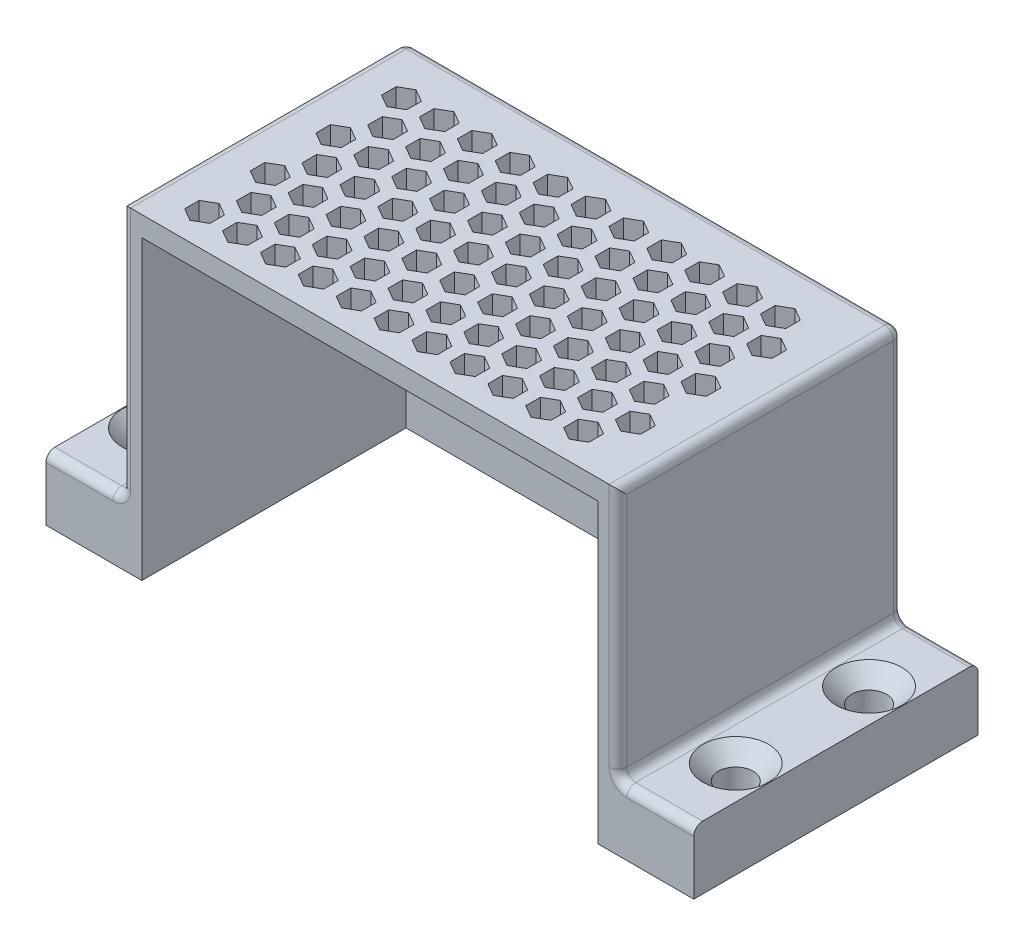
from build123d import *

# Parameters (mm, degrees)
SKETCH1_W                                       = 78.55
SKETCH1_H                                       = 45
BOSS_EXTRUDE1_DEPTH                             = 50.175
SHELL1_T                                        = -3.175
SKETCH2_W                                       = 45
SKETCH2_H                                       = 10
BOSS_EXTRUDE2_DEPTH                             = 12
FILLET1_R                                       = 1.4
FILLET2_R                                       = 1.4
CUT_EXTRUDE1_DEPTH                              = 12
FILLET3_R                                       = 1.4
CSK_FOR_M5_FLAT_HEAD_MACHINE_SCREW1_D           = 5.5
CSK_FOR_M5_FLAT_HEAD_MACHINE_SCREW1_DEPTH       = 10
CSK_FOR_M5_FLAT_HEAD_MACHINE_SCREW1_CSINK_D     = 10.4
CSK_FOR_M5_FLAT_HEAD_MACHINE_SCREW1_CSINK_ANGLE = 90


with BuildPart() as part:
    # Sketch1 → Boss-Extrude1 (new body)
    with BuildSketch(Plane(origin=(0, 0, 0), x_dir=(1, 0, 0), z_dir=(0, 1, 0))):
        Rectangle(SKETCH1_W, SKETCH1_H)
    extrude(amount=BOSS_EXTRUDE1_DEPTH)

    # Shell1
    shell1_openings = [part.faces().sort_by_distance(p)[0] for p in [
        (0, 0, 0),
        (0, 25.0875, 22.5),
    ]]
    offset(amount=SHELL1_T, openings=shell1_openings, kind=Kind.INTERSECTION)

    # Sketch2 → Boss-Extrude2 (add)
    with BuildSketch(Plane(origin=(39.275, 0, 0), x_dir=(0, 0, -1), z_dir=(1, 0, 0))):
        with Locations((0, 5)):
            Rectangle(SKETCH2_W, SKETCH2_H)
    boss_extrude2 = extrude(amount=BOSS_EXTRUDE2_DEPTH)

    # Fillet1
    fillet1_edges = [part.edges().sort_by_distance(p)[0] for p in [
        (39.275, 10, 0),
    ]]
    fillet(fillet1_edges, radius=FILLET1_R)

    # Mirror1: Boss-Extrude2 across plane
    add(boss_extrude2.mirror(Plane(origin=(0, 0, 0), x_dir=(0, 0, 1), z_dir=(1, 0, 0))))

    # Fillet2
    fillet2_edges = [part.edges().sort_by_distance(p)[0] for p in [
        (-39.275, 10, 0),
    ]]
    fillet(fillet2_edges, radius=FILLET2_R)

    # Sketch3 → Cut-Extrude1 (cut)
    with BuildSketch(Plane(origin=(0, 50.175, 0), x_dir=(1, 0, 0), z_dir=(0, 1, 0))):
        Polygon((-20.5, 7.649745962), (-20.5, 9.959147039), (-22.5, 11.113847577), (-24.5, 9.959147039), (-24.5, 7.649745962), (-22.5, 6.495045424), align=None)
        Polygon((-26.5, 7.649745962), (-26.5, 9.959147039), (-28.5, 11.113847577), (-30.5, 9.959147039), (-30.5, 7.649745962), (-28.5, 6.495045424), align=None)
        Polygon((-29.5, 12.845898385), (-29.5, 15.155299462), (-31.5, 16.31), (-33.5, 15.155299462), (-33.5, 12.845898385), (-31.5, 11.691197846), align=None)
        Polygon((-23.5, 12.845898385), (-23.5, 15.155299462), (-25.5, 16.31), (-27.5, 15.155299462), (-27.5, 12.845898385), (-25.5, 11.691197846), align=None)
        Polygon((-14.5, 7.649745962), (-14.5, 9.959147039), (-16.5, 11.113847577), (-18.5, 9.959147039), (-18.5, 7.649745962), (-16.5, 6.495045424), align=None)
        Polygon((-17.5, 12.845898385), (-17.5, 15.155299462), (-19.5, 16.31), (-21.5, 15.155299462), (-21.5, 12.845898385), (-19.5, 11.691197846), align=None)
        Polygon((-8.5, 7.649745962), (-8.5, 9.959147039), (-10.5, 11.113847577), (-12.5, 9.959147039), (-12.5, 7.649745962), (-10.5, 6.495045424), align=None)
        Polygon((-11.5, 12.845898385), (-11.5, 15.155299462), (-13.5, 16.31), (-15.5, 15.155299462), (-15.5, 12.845898385), (-13.5, 11.691197846), align=None)
        Polygon((-2.5, 7.649745962), (-2.5, 9.959147039), (-4.5, 11.113847577), (-6.5, 9.959147039), (-6.5, 7.649745962), (-4.5, 6.495045424), align=None)
        Polygon((-5.5, 12.845898385), (-5.5, 15.155299462), (-7.5, 16.31), (-9.5, 15.155299462), (-9.5, 12.845898385), (-7.5, 11.691197846), align=None)
        Polygon((3.5, 7.649745962), (3.5, 9.959147039), (1.5, 11.113847577), (-0.5, 9.959147039), (-0.5, 7.649745962), (1.5, 6.495045424), align=None)
        Polygon((0.5, 12.845898385), (0.5, 15.155299462), (-1.5, 16.31), (-3.5, 15.155299462), (-3.5, 12.845898385), (-1.5, 11.691197846), align=None)
        Polygon((9.5, 7.649745962), (9.5, 9.959147039), (7.5, 11.113847577), (5.5, 9.959147039), (5.5, 7.649745962), (7.5, 6.495045424), align=None)
        Polygon((6.5, 12.845898385), (6.5, 15.155299462), (4.5, 16.31), (2.5, 15.155299462), (2.5, 12.845898385), (4.5, 11.691197846), align=None)
        Polygon((15.5, 7.649745962), (15.5, 9.959147039), (13.5, 11.113847577), (11.5, 9.959147039), (11.5, 7.649745962), (13.5, 6.495045424), align=None)
        Polygon((12.5, 12.845898385), (12.5, 15.155299462), (10.5, 16.31), (8.5, 15.155299462), (8.5, 12.845898385), (10.5, 11.691197846), align=None)
        Polygon((21.5, 7.649745962), (21.5, 9.959147039), (19.5, 11.113847577), (17.5, 9.959147039), (17.5, 7.649745962), (19.5, 6.495045424), align=None)
        Polygon((18.5, 12.845898385), (18.5, 15.155299462), (16.5, 16.31), (14.5, 15.155299462), (14.5, 12.845898385), (16.5, 11.691197846), align=None)
        Polygon((27.5, 7.649745962), (27.5, 9.959147039), (25.5, 11.113847577), (23.5, 9.959147039), (23.5, 7.649745962), (25.5, 6.495045424), align=None)
        Polygon((24.5, 12.845898385), (24.5, 15.155299462), (22.5, 16.31), (20.5, 15.155299462), (20.5, 12.845898385), (22.5, 11.691197846), align=None)
        Polygon((33.5, 7.649745962), (33.5, 9.959147039), (31.5, 11.113847577), (29.5, 9.959147039), (29.5, 7.649745962), (31.5, 6.495045424), align=None)
        Polygon((30.5, 12.845898385), (30.5, 15.155299462), (28.5, 16.31), (26.5, 15.155299462), (26.5, 12.845898385), (28.5, 11.691197846), align=None)
        Polygon((-20.5, -2.740254038), (-20.5, -0.430852961), (-22.5, 0.723847577), (-24.5, -0.430852961), (-24.5, -2.740254038), (-22.5, -3.894954576), align=None)
        Polygon((-23.5, 2.455898385), (-23.5, 4.765299462), (-25.5, 5.92), (-27.5, 4.765299462), (-27.5, 2.455898385), (-25.5, 1.301197846), align=None)
        Polygon((-14.5, -2.740254038), (-14.5, -0.430852961), (-16.5, 0.723847577), (-18.5, -0.430852961), (-18.5, -2.740254038), (-16.5, -3.894954576), align=None)
        Polygon((-17.5, 2.455898385), (-17.5, 4.765299462), (-19.5, 5.92), (-21.5, 4.765299462), (-21.5, 2.455898385), (-19.5, 1.301197846), align=None)
        Polygon((-8.5, -2.740254038), (-8.5, -0.430852961), (-10.5, 0.723847577), (-12.5, -0.430852961), (-12.5, -2.740254038), (-10.5, -3.894954576), align=None)
        Polygon((-11.5, 2.455898385), (-11.5, 4.765299462), (-13.5, 5.92), (-15.5, 4.765299462), (-15.5, 2.455898385), (-13.5, 1.301197846), align=None)
        Polygon((-2.5, -2.740254038), (-2.5, -0.430852961), (-4.5, 0.723847577), (-6.5, -0.430852961), (-6.5, -2.740254038), (-4.5, -3.894954576), align=None)
        Polygon((-5.5, 2.455898385), (-5.5, 4.765299462), (-7.5, 5.92), (-9.5, 4.765299462), (-9.5, 2.455898385), (-7.5, 1.301197846), align=None)
        Polygon((3.5, -2.740254038), (3.5, -0.430852961), (1.5, 0.723847577), (-0.5, -0.430852961), (-0.5, -2.740254038), (1.5, -3.894954576), align=None)
        Polygon((0.5, 2.455898385), (0.5, 4.765299462), (-1.5, 5.92), (-3.5, 4.765299462), (-3.5, 2.455898385), (-1.5, 1.301197846), align=None)
        Polygon((9.5, -2.740254038), (9.5, -0.430852961), (7.5, 0.723847577), (5.5, -0.430852961), (5.5, -2.740254038), (7.5, -3.894954576), align=None)
        Polygon((6.5, 2.455898385), (6.5, 4.765299462), (4.5, 5.92), (2.5, 4.765299462), (2.5, 2.455898385), (4.5, 1.301197846), align=None)
        Polygon((15.5, -2.740254038), (15.5, -0.430852961), (13.5, 0.723847577), (11.5, -0.430852961), (11.5, -2.740254038), (13.5, -3.894954576), align=None)
        Polygon((12.5, 2.455898385), (12.5, 4.765299462), (10.5, 5.92), (8.5, 4.765299462), (8.5, 2.455898385), (10.5, 1.301197846), align=None)
        Polygon((21.5, -2.740254038), (21.5, -0.430852961), (19.5, 0.723847577), (17.5, -0.430852961), (17.5, -2.740254038), (19.5, -3.894954576), align=None)
        Polygon((18.5, 2.455898385), (18.5, 4.765299462), (16.5, 5.92), (14.5, 4.765299462), (14.5, 2.455898385), (16.5, 1.301197846), align=None)
        Polygon((27.5, -2.740254038), (27.5, -0.430852961), (25.5, 0.723847577), (23.5, -0.430852961), (23.5, -2.740254038), (25.5, -3.894954576), align=None)
        Polygon((24.5, 2.455898385), (24.5, 4.765299462), (22.5, 5.92), (20.5, 4.765299462), (20.5, 2.455898385), (22.5, 1.301197846), align=None)
        Polygon((33.5, -2.740254038), (33.5, -0.430852961), (31.5, 0.723847577), (29.5, -0.430852961), (29.5, -2.740254038), (31.5, -3.894954576), align=None)
        Polygon((30.5, 2.455898385), (30.5, 4.765299462), (28.5, 5.92), (26.5, 4.765299462), (26.5, 2.455898385), (28.5, 1.301197846), align=None)
        Polygon((-20.5, -13.130254038), (-20.5, -10.820852961), (-22.5, -9.666152423), (-24.5, -10.820852961), (-24.5, -13.130254038), (-22.5, -14.284954576), align=None)
        Polygon((-23.5, -7.934101615), (-23.5, -5.624700538), (-25.5, -4.47), (-27.5, -5.624700538), (-27.5, -7.934101615), (-25.5, -9.088802154), align=None)
        Polygon((-14.5, -13.130254038), (-14.5, -10.820852961), (-16.5, -9.666152423), (-18.5, -10.820852961), (-18.5, -13.130254038), (-16.5, -14.284954576), align=None)
        Polygon((-17.5, -7.934101615), (-17.5, -5.624700538), (-19.5, -4.47), (-21.5, -5.624700538), (-21.5, -7.934101615), (-19.5, -9.088802154), align=None)
        Polygon((-8.5, -13.130254038), (-8.5, -10.820852961), (-10.5, -9.666152423), (-12.5, -10.820852961), (-12.5, -13.130254038), (-10.5, -14.284954576), align=None)
        Polygon((-11.5, -7.934101615), (-11.5, -5.624700538), (-13.5, -4.47), (-15.5, -5.624700538), (-15.5, -7.934101615), (-13.5, -9.088802154), align=None)
        Polygon((-2.5, -13.130254038), (-2.5, -10.820852961), (-4.5, -9.666152423), (-6.5, -10.820852961), (-6.5, -13.130254038), (-4.5, -14.284954576), align=None)
        Polygon((-5.5, -7.934101615), (-5.5, -5.624700538), (-7.5, -4.47), (-9.5, -5.624700538), (-9.5, -7.934101615), (-7.5, -9.088802154), align=None)
        Polygon((3.5, -13.130254038), (3.5, -10.820852961), (1.5, -9.666152423), (-0.5, -10.820852961), (-0.5, -13.130254038), (1.5, -14.284954576), align=None)
        Polygon((0.5, -7.934101615), (0.5, -5.624700538), (-1.5, -4.47), (-3.5, -5.624700538), (-3.5, -7.934101615), (-1.5, -9.088802154), align=None)
        Polygon((9.5, -13.130254038), (9.5, -10.820852961), (7.5, -9.666152423), (5.5, -10.820852961), (5.5, -13.130254038), (7.5, -14.284954576), align=None)
        Polygon((6.5, -7.934101615), (6.5, -5.624700538), (4.5, -4.47), (2.5, -5.624700538), (2.5, -7.934101615), (4.5, -9.088802154), align=None)
        Polygon((15.5, -13.130254038), (15.5, -10.820852961), (13.5, -9.666152423), (11.5, -10.820852961), (11.5, -13.130254038), (13.5, -14.284954576), align=None)
        Polygon((12.5, -7.934101615), (12.5, -5.624700538), (10.5, -4.47), (8.5, -5.624700538), (8.5, -7.934101615), (10.5, -9.088802154), align=None)
        Polygon((21.5, -13.130254038), (21.5, -10.820852961), (19.5, -9.666152423), (17.5, -10.820852961), (17.5, -13.130254038), (19.5, -14.284954576), align=None)
        Polygon((18.5, -7.934101615), (18.5, -5.624700538), (16.5, -4.47), (14.5, -5.624700538), (14.5, -7.934101615), (16.5, -9.088802154), align=None)
        Polygon((27.5, -13.130254038), (27.5, -10.820852961), (25.5, -9.666152423), (23.5, -10.820852961), (23.5, -13.130254038), (25.5, -14.284954576), align=None)
        Polygon((24.5, -7.934101615), (24.5, -5.624700538), (22.5, -4.47), (20.5, -5.624700538), (20.5, -7.934101615), (22.5, -9.088802154), align=None)
        Polygon((33.5, -13.130254038), (33.5, -10.820852961), (31.5, -9.666152423), (29.5, -10.820852961), (29.5, -13.130254038), (31.5, -14.284954576), align=None)
        Polygon((30.5, -7.934101615), (30.5, -5.624700538), (28.5, -4.47), (26.5, -5.624700538), (26.5, -7.934101615), (28.5, -9.088802154), align=None)
        Polygon((-23.5, -18.324101615), (-23.5, -16.014700538), (-25.5, -14.86), (-27.5, -16.014700538), (-27.5, -18.324101615), (-25.5, -19.478802154), align=None)
        Polygon((-17.5, -18.324101615), (-17.5, -16.014700538), (-19.5, -14.86), (-21.5, -16.014700538), (-21.5, -18.324101615), (-19.5, -19.478802154), align=None)
        Polygon((-11.5, -18.324101615), (-11.5, -16.014700538), (-13.5, -14.86), (-15.5, -16.014700538), (-15.5, -18.324101615), (-13.5, -19.478802154), align=None)
        Polygon((-5.5, -18.324101615), (-5.5, -16.014700538), (-7.5, -14.86), (-9.5, -16.014700538), (-9.5, -18.324101615), (-7.5, -19.478802154), align=None)
        Polygon((0.5, -18.324101615), (0.5, -16.014700538), (-1.5, -14.86), (-3.5, -16.014700538), (-3.5, -18.324101615), (-1.5, -19.478802154), align=None)
        Polygon((6.5, -18.324101615), (6.5, -16.014700538), (4.5, -14.86), (2.5, -16.014700538), (2.5, -18.324101615), (4.5, -19.478802154), align=None)
        Polygon((12.5, -18.324101615), (12.5, -16.014700538), (10.5, -14.86), (8.5, -16.014700538), (8.5, -18.324101615), (10.5, -19.478802154), align=None)
        Polygon((18.5, -18.324101615), (18.5, -16.014700538), (16.5, -14.86), (14.5, -16.014700538), (14.5, -18.324101615), (16.5, -19.478802154), align=None)
        Polygon((24.5, -18.324101615), (24.5, -16.014700538), (22.5, -14.86), (20.5, -16.014700538), (20.5, -18.324101615), (22.5, -19.478802154), align=None)
        Polygon((30.5, -18.324101615), (30.5, -16.014700538), (28.5, -14.86), (26.5, -16.014700538), (26.5, -18.324101615), (28.5, -19.478802154), align=None)
        Polygon((-26.5, -2.740254038), (-26.5, -0.430852961), (-28.5, 0.723847577), (-30.5, -0.430852961), (-30.5, -2.740254038), (-28.5, -3.894954576), align=None)
        Polygon((-29.5, 2.455898385), (-29.5, 4.765299462), (-31.5, 5.92), (-33.5, 4.765299462), (-33.5, 2.455898385), (-31.5, 1.301197846), align=None)
        Polygon((-26.5, -13.130254038), (-26.5, -10.820852961), (-28.5, -9.666152423), (-30.5, -10.820852961), (-30.5, -13.130254038), (-28.5, -14.284954576), align=None)
        Polygon((-29.5, -7.934101615), (-29.5, -5.624700538), (-31.5, -4.47), (-33.5, -5.624700538), (-33.5, -7.934101615), (-31.5, -9.088802154), align=None)
        Polygon((-29.5, -18.324101615), (-29.5, -16.014700538), (-31.5, -14.86), (-33.5, -16.014700538), (-33.5, -18.324101615), (-31.5, -19.478802154), align=None)
    extrude(amount=-CUT_EXTRUDE1_DEPTH, mode=Mode.SUBTRACT)

    # Fillet3
    fillet3_edges = [part.edges().sort_by_distance(p)[0] for p in [
        (39.275, 50.175, 0),
        (0, 50.175, -22.5),
        (45.975, 10, 22.5),
        (45.975, 10, -22.5),
        (39.685050506, 10.410050506, 22.5),
        (39.685050506, 10.410050506, -22.5),
        (-45.975, 10, 22.5),
        (-45.975, 10, -22.5),
        (-39.275, 50.175, 0),
        (-39.685050506, 10.410050506, 22.5),
        (-39.685050506, 10.410050506, -22.5),
        (-39.275, 30.7875, -22.5),
        (39.275, 30.7875, -22.5),
        (39.275, 30.7875, 22.5),
        (-39.275, 30.7875, 22.5),
    ]]
    fillet(fillet3_edges, radius=FILLET3_R)

    # CSK for M5 Flat Head Machine Screw1
    with Locations(Plane(origin=(0, 10, 0), x_dir=(1, 0, 0), z_dir=(0, 1, 0))):
        with Locations((-45.975, -10.55), (-45.975, 10.55)):
            csk_for_m5_flat_head_machine_screw1 = CounterSinkHole(CSK_FOR_M5_FLAT_HEAD_MACHINE_SCREW1_D / 2, CSK_FOR_M5_FLAT_HEAD_MACHINE_SCREW1_CSINK_D / 2, depth=CSK_FOR_M5_FLAT_HEAD_MACHINE_SCREW1_DEPTH, counter_sink_angle=CSK_FOR_M5_FLAT_HEAD_MACHINE_SCREW1_CSINK_ANGLE)

    # Mirror2: CSK for M5 Flat Head Machine Screw1 across plane
    add(csk_for_m5_flat_head_machine_screw1.mirror(Plane(origin=(0, 0, 0), x_dir=(0, 0, 1), z_dir=(1, 0, 0))), mode=Mode.SUBTRACT)


solid = part.part
